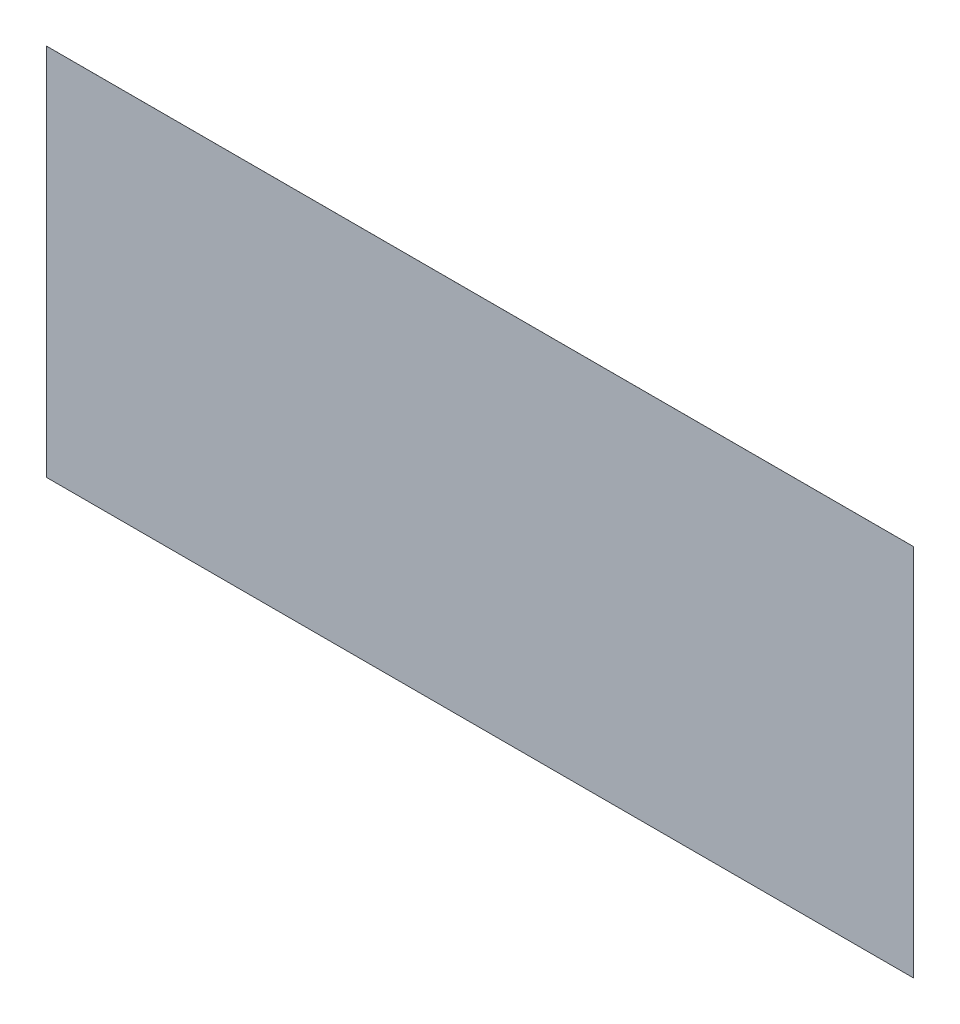
from build123d import *

# Parameters (mm, degrees)
SKETCH1_W           = 10.12
SKETCH1_H           = 4.36
BOSS_EXTRUDE1_DEPTH = 0.00025


with BuildPart() as part:
    # Sketch1 → Boss-Extrude1 (new body)
    with BuildSketch(Plane.XY):
        with Locations((0, -0.295)):
            Rectangle(SKETCH1_W, SKETCH1_H)
    extrude(amount=BOSS_EXTRUDE1_DEPTH)


solid = part.part
